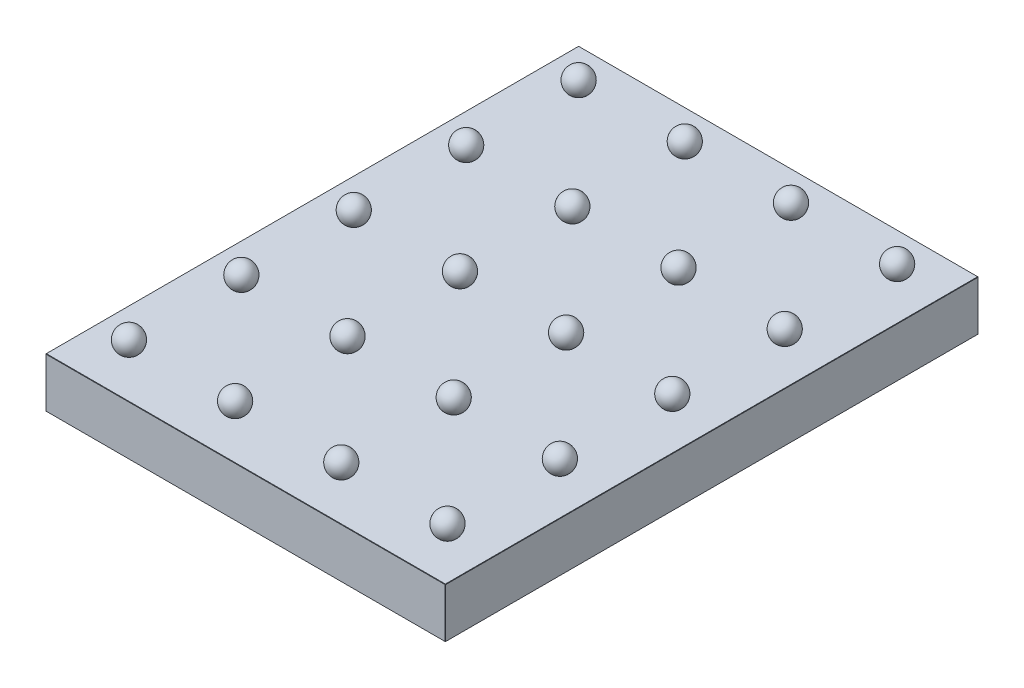
from build123d import *

# Parameters (mm, degrees)
SKETCH1_W            = 304.8
SKETCH1_H            = 406.4
EXTRUDE1_DEPTH       = 38.1
SKETCH7_W            = 304.8
SKETCH7_H            = 406.4
EXTRUDE2_DEPTH       = 22.225
CUT_EXTRUDE3_DEPTH   = 23.495
SKETCH10_W           = 91.821
SKETCH10_H           = 115.951
CUT_EXTRUDE4_DEPTH   = 11.43
FILLET1_R            = 9.525
FILLET2_R            = 4.7752
FILLET3_R            = 4.7752
FILLET4_R            = 4.7752
CHAMFER1_SIZE        = 0.254
LPATTERN1_COUNT      = 4
LPATTERN1_PITCH      = 80.9625
LPATTERN1_COUNT_DIR2 = 5
LPATTERN1_PITCH_DIR2 = 85.725


with BuildPart() as part:
    # Sketch1 → Extrude1 (new body)
    with BuildSketch(Plane(origin=(0, 0, 0), x_dir=(1, 0, 0), z_dir=(0, 1, 0))):
        Rectangle(SKETCH1_W, SKETCH1_H)
    extrude(amount=-EXTRUDE1_DEPTH)

    # Sketch7 → Extrude2 (add)
    with BuildSketch(Plane(origin=(0, 0, 0), x_dir=(-1, 0, 0), z_dir=(0, 1, 0))):
        Rectangle(SKETCH7_W, SKETCH7_H)
    extrude(amount=-EXTRUDE2_DEPTH)

    # Sketch9 → Cut-Extrude3 (cut)
    with BuildSketch(Plane.XZ.offset(38.1)):
        with BuildLine():
            Line((26.8605, 50.9905), (-26.8605, 50.9905))
            ThreePointArc((-26.8605, 50.9905), (-35.391743315, 47.456743315), (-38.9255, 38.9255))
            Line((-38.9255, 38.9255), (-38.9255, -38.9255))
            ThreePointArc((-38.9255, -38.9255), (-35.391743315, -47.456743315), (-26.8605, -50.9905))
            Line((-26.8605, -50.9905), (26.8605, -50.9905))
            ThreePointArc((26.8605, -50.9905), (35.391743315, -47.456743315), (38.9255, -38.9255))
            Line((38.9255, -38.9255), (38.9255, 38.9255))
            ThreePointArc((38.9255, 38.9255), (35.391743315, 47.456743315), (26.8605, 50.9905))
        make_face()
        with BuildLine():
            Line((-38.9255, 149.225), (-38.9255, 112.0775))
            ThreePointArc((-38.9255, 112.0775), (-35.391743315, 103.546256685), (-26.8605, 100.0125))
            Line((-26.8605, 100.0125), (26.8605, 100.0125))
            ThreePointArc((26.8605, 100.0125), (35.391743315, 103.546256685), (38.9255, 112.0775))
            Line((38.9255, 112.0775), (38.9255, 149.225))
            ThreePointArc((38.9255, 149.225), (30.393916528, 161.221428787), (16.261830134, 157.099978273))
            ThreePointArc((16.261830134, 157.099978273), (0, 149.225), (-16.261830134, 157.099978273))
            ThreePointArc((-16.261830134, 157.099978273), (-30.393916528, 161.221428787), (-38.9255, 149.225))
        make_face()
        with BuildLine():
            Line((129.8575, 50.9905), (100.0125, 50.9905))
            ThreePointArc((100.0125, 50.9905), (91.481256685, 47.456743315), (87.9475, 38.9255))
            Line((87.9475, 38.9255), (87.9475, -38.9255))
            ThreePointArc((87.9475, -38.9255), (91.481256685, -47.456743315), (100.0125, -50.9905))
            Line((100.0125, -50.9905), (129.8575, -50.9905))
            ThreePointArc((129.8575, -50.9905), (138.388743315, -47.456743315), (141.9225, -38.9255))
            Line((141.9225, -38.9255), (141.9225, 38.9255))
            ThreePointArc((141.9225, 38.9255), (138.388743315, 47.456743315), (129.8575, 50.9905))
        make_face()
        with BuildLine():
            Line((129.8575, 192.7225), (100.0125, 192.7225))
            ThreePointArc((100.0125, 192.7225), (91.481256685, 189.188743315), (87.9475, 180.6575))
            Line((87.9475, 180.6575), (87.9475, 112.0775))
            ThreePointArc((87.9475, 112.0775), (91.481256685, 103.546256685), (100.0125, 100.0125))
            Line((100.0125, 100.0125), (129.8575, 100.0125))
            ThreePointArc((129.8575, 100.0125), (138.388743315, 103.546256685), (141.9225, 112.0775))
            Line((141.9225, 112.0775), (141.9225, 180.6575))
            ThreePointArc((141.9225, 180.6575), (138.388743315, 189.188743315), (129.8575, 192.7225))
        make_face()
        with BuildLine():
            Line((-87.9475, -156.845), (-87.9475, -112.0775))
            ThreePointArc((-87.9475, -112.0775), (-91.481256685, -103.546256685), (-100.0125, -100.0125))
            Line((-100.0125, -100.0125), (-129.8575, -100.0125))
            ThreePointArc((-129.8575, -100.0125), (-138.388743315, -103.546256685), (-141.9225, -112.0775))
            Line((-141.9225, -112.0775), (-141.9225, -142.108424226))
            ThreePointArc((-141.9225, -142.108424226), (-138.946704897, -149.292629123), (-131.7625, -152.268424226))
            Line((-131.7625, -152.268424226), (-127, -152.268424226))
            ThreePointArc((-127, -152.268424226), (-115.399464126, -155.056013345), (-106.332068225, -162.81007146))
            ThreePointArc((-106.332068225, -162.81007146), (-94.971899034, -166.509036764), (-87.9475, -156.845))
        make_face()
        with BuildLine():
            Line((87.9475, -112.0775), (87.9475, -156.845))
            ThreePointArc((87.9475, -156.845), (94.971899034, -166.509036764), (106.332068225, -162.81007146))
            ThreePointArc((106.332068225, -162.81007146), (115.399464126, -155.056013345), (127, -152.268424226))
            Line((127, -152.268424226), (131.7625, -152.268424226))
            ThreePointArc((131.7625, -152.268424226), (138.946704897, -149.292629123), (141.9225, -142.108424226))
            Line((141.9225, -142.108424226), (141.9225, -112.0775))
            ThreePointArc((141.9225, -112.0775), (138.388743315, -103.546256685), (129.8575, -100.0125))
            Line((129.8575, -100.0125), (100.0125, -100.0125))
            ThreePointArc((100.0125, -100.0125), (91.481256685, -103.546256685), (87.9475, -112.0775))
        make_face()
        with BuildLine():
            Line((-38.9255, -112.0775), (-38.9255, -180.6575))
            ThreePointArc((-38.9255, -180.6575), (-35.391743315, -189.188743315), (-26.8605, -192.7225))
            Line((-26.8605, -192.7225), (26.8605, -192.7225))
            ThreePointArc((26.8605, -192.7225), (35.391743315, -189.188743315), (38.9255, -180.6575))
            Line((38.9255, -180.6575), (38.9255, -112.0775))
            ThreePointArc((38.9255, -112.0775), (35.391743315, -103.546256685), (26.8605, -100.0125))
            Line((26.8605, -100.0125), (-26.8605, -100.0125))
            ThreePointArc((-26.8605, -100.0125), (-35.391743315, -103.546256685), (-38.9255, -112.0775))
        make_face()
        with BuildLine():
            Line((-87.9475, 112.0775), (-87.9475, 180.6575))
            ThreePointArc((-87.9475, 180.6575), (-91.481256685, 189.188743315), (-100.0125, 192.7225))
            Line((-100.0125, 192.7225), (-129.8575, 192.7225))
            ThreePointArc((-129.8575, 192.7225), (-138.388743315, 189.188743315), (-141.9225, 180.6575))
            Line((-141.9225, 180.6575), (-141.9225, 112.0775))
            ThreePointArc((-141.9225, 112.0775), (-138.388743315, 103.546256685), (-129.8575, 100.0125))
            Line((-129.8575, 100.0125), (-100.0125, 100.0125))
            ThreePointArc((-100.0125, 100.0125), (-91.481256685, 103.546256685), (-87.9475, 112.0775))
        make_face()
        with BuildLine():
            Line((-87.9475, -38.9255), (-87.9475, 38.9255))
            ThreePointArc((-87.9475, 38.9255), (-91.481256685, 47.456743315), (-100.0125, 50.9905))
            Line((-100.0125, 50.9905), (-129.8575, 50.9905))
            ThreePointArc((-129.8575, 50.9905), (-138.388743315, 47.456743315), (-141.9225, 38.9255))
            Line((-141.9225, 38.9255), (-141.9225, -38.9255))
            ThreePointArc((-141.9225, -38.9255), (-138.388743315, -47.456743315), (-129.8575, -50.9905))
            Line((-129.8575, -50.9905), (-100.0125, -50.9905))
            ThreePointArc((-100.0125, -50.9905), (-91.481256685, -47.456743315), (-87.9475, -38.9255))
        make_face()
    extrude(amount=-CUT_EXTRUDE3_DEPTH, mode=Mode.SUBTRACT)

    # Sketch10 → Cut-Extrude4 (cut)
    with BuildSketch(Plane.XZ.offset(38.1)):
        Polygon((80.9625, 57.9755), (80.9625, -57.9755), (137.795, -57.9755), (137.795, -93.0275), (80.9625, -93.0275), (80.9625, -188.595), (45.9105, -188.595), (45.9105, -93.0275), (-45.9105, -93.0275), (-45.9105, -188.595), (-80.9625, -188.595), (-80.9625, -93.0275), (-137.795, -93.0275), (-137.795, -57.9755), (-80.9625, -57.9755), (-80.9625, 57.9755), (-137.795, 57.9755), (-137.795, 93.0275), (-80.9625, 93.0275), (-80.9625, 188.595), (-45.9105, 188.595), (-45.9105, 93.0275), (45.9105, 93.0275), (45.9105, 188.595), (80.9625, 188.595), (80.9625, 93.0275), (137.795, 93.0275), (137.795, 57.9755), align=None)
        Rectangle(SKETCH10_W, SKETCH10_H, mode=Mode.SUBTRACT)
    extrude(amount=-CUT_EXTRUDE4_DEPTH, mode=Mode.SUBTRACT)

    # Fillet1
    fillet1_edges = [part.edges().sort_by_distance(p)[0] for p in [
        (80.9625, -32.385, 93.0275),
        (80.9625, -32.385, 57.9755),
        (80.9625, -32.385, -57.9755),
        (80.9625, -32.385, -93.0275),
        (45.9105, -32.385, -93.0275),
        (-45.9105, -32.385, -93.0275),
        (-80.9625, -32.385, -93.0275),
        (-80.9625, -32.385, -57.9755),
        (-80.9625, -32.385, 57.9755),
        (-80.9625, -32.385, 93.0275),
        (-45.9105, -32.385, 93.0275),
        (45.9105, -32.385, 93.0275),
        (45.9105, -32.385, -57.9755),
        (-45.9105, -32.385, -57.9755),
        (-45.9105, -32.385, 57.9755),
        (45.9105, -32.385, 57.9755),
    ]]
    fillet(fillet1_edges, radius=FILLET1_R)

    # Fillet2
    fillet2_edges = [part.edges().sort_by_distance(p)[0] for p in [
        (80.9625, -32.385, 188.595),
        (137.795, -32.385, 93.0275),
        (137.795, -32.385, 57.9755),
        (137.795, -32.385, -57.9755),
        (137.795, -32.385, -93.0275),
        (80.9625, -32.385, -188.595),
        (45.9105, -32.385, -188.595),
        (-45.9105, -32.385, -188.595),
        (-80.9625, -32.385, -188.595),
        (-137.795, -32.385, -93.0275),
        (-137.795, -32.385, -57.9755),
        (-137.795, -32.385, 57.9755),
        (-137.795, -32.385, 93.0275),
        (-80.9625, -32.385, 188.595),
        (-45.9105, -32.385, 188.595),
        (45.9105, -32.385, 188.595),
    ]]
    fillet(fillet2_edges, radius=FILLET2_R)

    # Fillet3
    fillet3_edges = [part.edges().sort_by_distance(p)[0] for p in [
        (-80.9625, -26.67, -143.18615),
        (-111.75365, -26.67, -57.9755),
        (-80.9625, -26.67, 0),
        (-111.75365, -26.67, 93.0275),
        (45.9105, -26.67, -143.18615),
        (0, -26.67, -93.0275),
        (0, -26.67, -57.9755),
        (45.9105, -26.67, 0),
        (0, -26.67, 57.9755),
        (0, -26.67, 93.0275),
        (-45.9105, -26.67, 0),
        (-45.9105, -26.67, 143.18615),
        (111.75365, -26.67, -93.0275),
        (80.9625, -26.67, 0),
        (111.75365, -26.67, 57.9755),
        (80.9625, -26.67, 143.18615),
        (-83.752307909, -26.67, -95.817307909),
        (-83.752307909, -26.67, -55.185692091),
        (-83.752307909, -26.67, 55.185692091),
        (-83.752307909, -26.67, 95.817307909),
        (43.120692091, -26.67, -95.817307909),
        (43.120692091, -26.67, -55.185692091),
        (43.120692091, -26.67, 55.185692091),
        (43.120692091, -26.67, 95.817307909),
        (-43.120692091, -26.67, -95.817307909),
        (-43.120692091, -26.67, -55.185692091),
        (-43.120692091, -26.67, 55.185692091),
        (-43.120692091, -26.67, 95.817307909),
        (83.752307909, -26.67, -95.817307909),
        (83.752307909, -26.67, -55.185692091),
        (83.752307909, -26.67, 55.185692091),
        (83.752307909, -26.67, 95.817307909),
        (63.4365, -26.67, -188.595),
        (111.75365, -26.67, 93.0275),
        (63.4365, -26.67, 188.595),
        (45.9105, -26.67, 143.18615),
        (-63.4365, -26.67, 188.595),
        (-80.9625, -26.67, 143.18615),
        (-137.795, -26.67, 75.5015),
        (-111.75365, -26.67, 57.9755),
        (-137.795, -26.67, -75.5015),
        (-111.75365, -26.67, -93.0275),
        (-63.4365, -26.67, -188.595),
        (-45.9105, -26.67, -143.18615),
        (80.9625, -26.67, -143.18615),
        (137.795, -26.67, -75.5015),
        (111.75365, -26.67, -57.9755),
        (137.795, -26.67, 75.5015),
        (79.563876302, -26.67, 187.196376302),
        (136.396376302, -26.67, 91.628876302),
        (136.396376302, -26.67, -59.374123698),
        (-47.309123698, -26.67, 187.196376302),
        (47.309123698, -26.67, 187.196376302),
        (-79.563876302, -26.67, 187.196376302),
        (-136.396376302, -26.67, 91.628876302),
        (-136.396376302, -26.67, -59.374123698),
        (136.396376302, -26.67, 59.374123698),
        (136.396376302, -26.67, -91.628876302),
        (79.563876302, -26.67, -187.196376302),
        (-47.309123698, -26.67, -187.196376302),
        (-79.563876302, -26.67, -187.196376302),
        (-136.396376302, -26.67, -91.628876302),
        (-136.396376302, -26.67, 59.374123698),
        (47.309123698, -26.67, -187.196376302),
    ]]
    fillet(fillet3_edges, radius=FILLET3_R)

    # Fillet4
    fillet4_edges = [part.edges().sort_by_distance(p)[0] for p in [
        (35.391743315, -14.605, -47.456743315),
        (0, -14.605, -50.9905),
        (-35.391743315, -14.605, -47.456743315),
        (-38.9255, -14.605, 0),
        (-35.391743315, -14.605, 47.456743315),
        (0, -14.605, 50.9905),
        (35.391743315, -14.605, 47.456743315),
        (38.9255, -14.605, 0),
        (91.481256685, -14.605, 189.188743315),
        (114.935, -14.605, 192.7225),
        (138.388743315, -14.605, 189.188743315),
        (141.9225, -14.605, 146.3675),
        (138.388743315, -14.605, 103.546256685),
        (114.935, -14.605, 100.0125),
        (91.481256685, -14.605, 103.546256685),
        (87.9475, -14.605, 146.3675),
        (-91.481256685, -14.605, 103.546256685),
        (-114.935, -14.605, 100.0125),
        (-138.388743315, -14.605, 103.546256685),
        (-141.9225, -14.605, 146.3675),
        (-138.388743315, -14.605, 189.188743315),
        (-114.935, -14.605, 192.7225),
        (-91.481256685, -14.605, 189.188743315),
        (-87.9475, -14.605, 146.3675),
        (-91.481256685, -14.605, 47.456743315),
        (-87.9475, -14.605, 0),
        (-91.481256685, -14.605, -47.456743315),
        (-114.935, -14.605, -50.9905),
        (-138.388743315, -14.605, -47.456743315),
        (-141.9225, -14.605, 0),
        (-138.388743315, -14.605, 47.456743315),
        (-114.935, -14.605, 50.9905),
        (-91.481256685, -14.605, -103.546256685),
        (-87.9475, -14.605, -134.46125),
        (-94.971899034, -14.605, -166.509036764),
        (-115.399464126, -14.605, -155.056013345),
        (-129.38125, -14.605, -152.268424226),
        (-138.946704897, -14.605, -149.292629123),
        (-141.9225, -14.605, -127.092962113),
        (-138.388743315, -14.605, -103.546256685),
        (-114.935, -14.605, -100.0125),
        (-30.393916528, -14.605, 161.221428787),
        (0, -14.605, 149.225),
        (30.393916528, -14.605, 161.221428787),
        (38.9255, -14.605, 130.65125),
        (35.391743315, -14.605, 103.546256685),
        (0, -14.605, 100.0125),
        (-35.391743315, -14.605, 103.546256685),
        (-38.9255, -14.605, 130.65125),
        (138.946704897, -14.605, -149.292629123),
        (129.38125, -14.605, -152.268424226),
        (115.399464126, -14.605, -155.056013345),
        (94.971899034, -14.605, -166.509036764),
        (87.9475, -14.605, -134.46125),
        (91.481256685, -14.605, -103.546256685),
        (114.935, -14.605, -100.0125),
        (138.388743315, -14.605, -103.546256685),
        (141.9225, -14.605, -127.092962113),
        (35.391743315, -14.605, -103.546256685),
        (38.9255, -14.605, -146.3675),
        (35.391743315, -14.605, -189.188743315),
        (0, -14.605, -192.7225),
        (-35.391743315, -14.605, -189.188743315),
        (-38.9255, -14.605, -146.3675),
        (-35.391743315, -14.605, -103.546256685),
        (0, -14.605, -100.0125),
        (138.388743315, -14.605, -47.456743315),
        (114.935, -14.605, -50.9905),
        (91.481256685, -14.605, -47.456743315),
        (87.9475, -14.605, 0),
        (91.481256685, -14.605, 47.456743315),
        (114.935, -14.605, 50.9905),
        (138.388743315, -14.605, 47.456743315),
        (141.9225, -14.605, 0),
    ]]
    fillet(fillet4_edges, radius=FILLET4_R)

    # Chamfer1
    chamfer1_edges = [part.edges().sort_by_distance(p)[0] for p in [
        (152.4, -38.1, 0),
        (0, -38.1, -203.2),
        (-152.4, -38.1, 0),
        (0, 0, -203.2),
        (152.4, 0, 0),
        (0, 0, 203.2),
        (-152.4, 0, 0),
        (0, -38.1, 203.2),
        (-152.4, -19.05, -203.2),
        (152.4, -19.05, -203.2),
        (152.4, -19.05, 203.2),
        (-152.4, -19.05, 203.2),
    ]]
    chamfer(chamfer1_edges, length=CHAMFER1_SIZE)

    # Sketch12 → Revolve1 (revolve)
    with BuildSketch(Plane(origin=(-120.396, 0, 0), x_dir=(0, 0, -1), z_dir=(1, 0, 0))):
        with BuildLine():
            Line((171.196, 0), (172.7835, 0))
            ThreePointArc((172.7835, 0), (180.68763573, 10.188316785), (171.196, 18.916776656))
            Line((171.196, 18.916776656), (171.196, 0))
        make_face()
    revolve1 = revolve(axis=Axis((-120.396, 0, -171.196), (0, 1, 0)))

    # LPattern1: Revolve1 4 × 5
    with Locations(*[(i * LPATTERN1_PITCH, 0, j * LPATTERN1_PITCH_DIR2) for i in range(LPATTERN1_COUNT) for j in range(LPATTERN1_COUNT_DIR2) if (i, j) != (0, 0)]):
        add(revolve1)


solid = part.part
